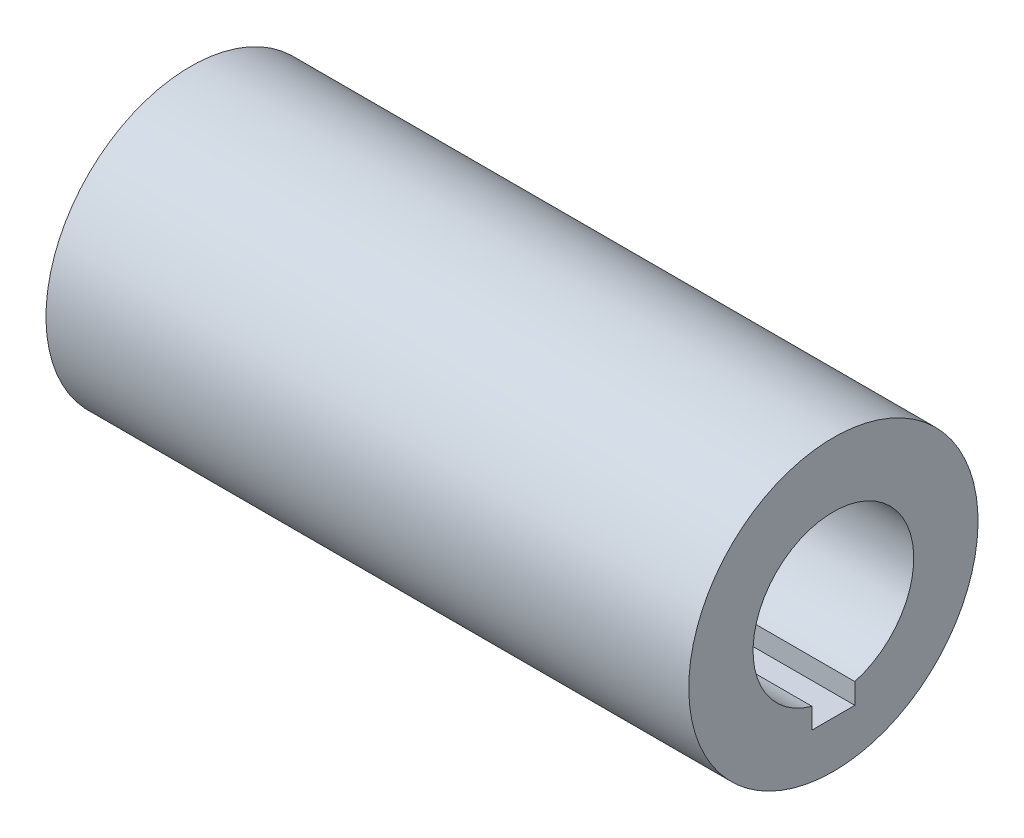
from build123d import *

# Parameters (mm, degrees)
IZIM1_W               = 120
IZIM1_H               = 12
IZIM2_W               = 120
IZIM2_H               = 8
KES_EKSTR_ZYON1_DEPTH = 18.3


with BuildPart() as part:
    # Çizim1 → Döndür1 (revolve)
    with BuildSketch(Plane.XY):
        with Locations((0, 21)):
            Rectangle(IZIM1_W, IZIM1_H)
    revolve(axis=Axis((-60, 0, 0), (1, 0, 0)))

    # Çizim2 → Kes-Ekstrüzyon1 (cut)
    with BuildSketch(Plane(origin=(0, 0, 0), x_dir=(1, 0, 0), z_dir=(0, 1, 0))):
        Rectangle(IZIM2_W, IZIM2_H)
    extrude(amount=-KES_EKSTR_ZYON1_DEPTH, mode=Mode.SUBTRACT)


solid = part.part
